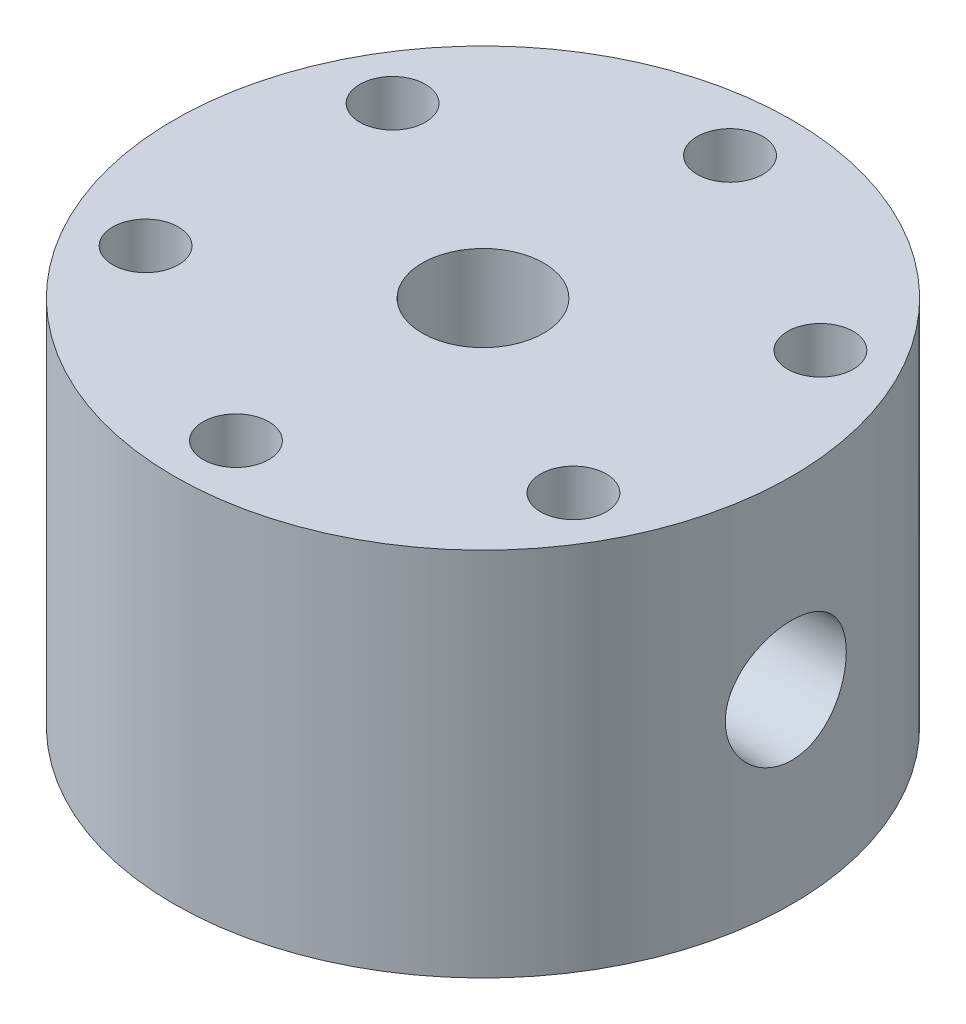
from build123d import *

# Parameters (mm, degrees)
M14X1_5_TAPPED_HOLE1_D              = 12.5
M14X1_5_TAPPED_HOLE1_DEPTH          = 25.4
M14X1_5_TAPPED_HOLE1_TIP            = 3.755378869
F_1_16_0_0625_DIAMETER_HOLE1_D      = 1.5875
F_1_16_0_0625_DIAMETER_HOLE1_DEPTH  = 28.575
F_1_16_0_0625_DIAMETER_HOLE1_TIP    = 0.476933116
F_3_32_0_09375_DIAMETER_HOLE1_D     = 2.38125
F_3_32_0_09375_DIAMETER_HOLE1_DEPTH = 28.702
F_3_32_0_09375_DIAMETER_HOLE1_TIP   = 0.715399675
F_1_4_CLEARANCE_HOLE1_D             = 6.7564
CIRPATTERN1_COUNT                   = 6
F_1_32_0_03125_DIAMETER_HOLE1_D     = 0.79375
F_1_32_0_03125_DIAMETER_HOLE1_DEPTH = 28.575
F_1_32_0_03125_DIAMETER_HOLE1_TIP   = 0.238466558


with BuildPart() as part:
    # Sketch1 → Revolve1 (revolve)
    with BuildSketch(Plane.XY):
        Polygon((-3.81, 0), (-8.0645, 0), (-8.0645, 2.032), (-11.1125, 2.032), (-11.1125, 0), (-12.7, 0), (-12.7, -6.35), (-31.75, -6.35), (-31.75, 31.75), (-3.81, 31.75), align=None)
    revolve(axis=Axis((0, 0, 0), (0, 1, 0)))

    # M14x1.5 Tapped Hole1
    with Locations(Plane(origin=(0, 31.75, 0), x_dir=(1, 0, 0), z_dir=(0, 1, 0))):
        with Locations((0, 0)):
            Hole(M14X1_5_TAPPED_HOLE1_D / 2, depth=M14X1_5_TAPPED_HOLE1_DEPTH)
            with Locations((0, 0, -(M14X1_5_TAPPED_HOLE1_DEPTH + M14X1_5_TAPPED_HOLE1_TIP / 2))):  # 118° drill point
                Cone(0, M14X1_5_TAPPED_HOLE1_D / 2, M14X1_5_TAPPED_HOLE1_TIP, mode=Mode.SUBTRACT)

    # Sketch6 → 1/4 NPT Tapped Hole1 (revolve, cut)
    with BuildSketch(Plane(origin=(31.75, 12.7, 0), x_dir=(0, 0, -1), z_dir=(0, 1, 0))):
        Polygon((0, 0), (0, 20.360347279), (5.5626, 17.018), (5.5626, 9.906), (5.943685794, 9.906), (6.2402847, 0), align=None)
    revolve(axis=Axis((38.1, 12.7, 0), (-1, 0, 0)), mode=Mode.SUBTRACT)

    # Sketch8 → 1/4 NPT Tapped Hole2 (revolve, cut)
    with BuildSketch(Plane(origin=(-31.75, 12.7, 0), x_dir=(0, 0, 1), z_dir=(0, 1, 0))):
        Polygon((0, 0), (0, 20.360347279), (5.5626, 17.018), (5.5626, 9.906), (5.943685794, 9.906), (6.2402847, 0), align=None)
    revolve(axis=Axis((-38.1, 12.7, 0), (1, 0, 0)), mode=Mode.SUBTRACT)

    # 1/16 (0.0625) Diameter Hole1
    with Locations(Plane(origin=(31.75, 0, 0), x_dir=(0, 0, -1), z_dir=(1, 0, 0))):
        with Locations((0, 12.7)):
            Hole(F_1_16_0_0625_DIAMETER_HOLE1_D / 2, depth=F_1_16_0_0625_DIAMETER_HOLE1_DEPTH)
            with Locations((0, 0, -(F_1_16_0_0625_DIAMETER_HOLE1_DEPTH + F_1_16_0_0625_DIAMETER_HOLE1_TIP / 2))):  # 118° drill point
                Cone(0, F_1_16_0_0625_DIAMETER_HOLE1_D / 2, F_1_16_0_0625_DIAMETER_HOLE1_TIP, mode=Mode.SUBTRACT)

    # 3/32 (0.09375) Diameter Hole1
    with Locations(Plane.ZY.offset(31.75)):
        with Locations((0, 12.7)):
            Hole(F_3_32_0_09375_DIAMETER_HOLE1_D / 2, depth=F_3_32_0_09375_DIAMETER_HOLE1_DEPTH)
            with Locations((0, 0, -(F_3_32_0_09375_DIAMETER_HOLE1_DEPTH + F_3_32_0_09375_DIAMETER_HOLE1_TIP / 2))):  # 118° drill point
                Cone(0, F_3_32_0_09375_DIAMETER_HOLE1_D / 2, F_3_32_0_09375_DIAMETER_HOLE1_TIP, mode=Mode.SUBTRACT)

    # 1/4 Clearance Hole1 (through all)
    with Locations(Plane(origin=(0, 31.75, 0), x_dir=(1, 0, 0), z_dir=(0, 1, 0))):
        with Locations((21.997045256, 12.7)):
            f_1_4_clearance_hole1 = Hole(F_1_4_CLEARANCE_HOLE1_D / 2)

    # CirPattern1: 1/4 Clearance Hole1 ×6 about axis
    cirpattern1_axis = Axis((0, 0, 0), (0, 1, 0))
    for i in range(1, CIRPATTERN1_COUNT):
        add(f_1_4_clearance_hole1.rotate(cirpattern1_axis, i * 360 / CIRPATTERN1_COUNT), mode=Mode.SUBTRACT)

    # Sketch18 → 1/4 NPT Tapped Hole3 (revolve, cut)
    with BuildSketch(Plane(origin=(15.875, 12.7, -27.49630657), x_dir=(-0.866025404, 0, -0.5), z_dir=(0, 1, 0))):
        Polygon((0, 0), (0, 19.852347279), (5.5626, 16.51), (5.5626, 12.7), (6.557983593, 12.7), (6.9382386, 0), align=None)
    revolve(axis=Axis((19.05, 12.7, -32.995567884), (-0.5, 0, 0.866025404)), mode=Mode.SUBTRACT)

    # 1/32 (0.03125) Diameter Hole1
    with Locations(Plane(origin=(15.875, 0, -27.49630657), x_dir=(0, -1, 0), z_dir=(0.5, 0, -0.866025404))):
        with Locations((-12.7, 0)):
            Hole(F_1_32_0_03125_DIAMETER_HOLE1_D / 2, depth=F_1_32_0_03125_DIAMETER_HOLE1_DEPTH)
            with Locations((0, 0, -(F_1_32_0_03125_DIAMETER_HOLE1_DEPTH + F_1_32_0_03125_DIAMETER_HOLE1_TIP / 2))):  # 118° drill point
                Cone(0, F_1_32_0_03125_DIAMETER_HOLE1_D / 2, F_1_32_0_03125_DIAMETER_HOLE1_TIP, mode=Mode.SUBTRACT)


solid = part.part
